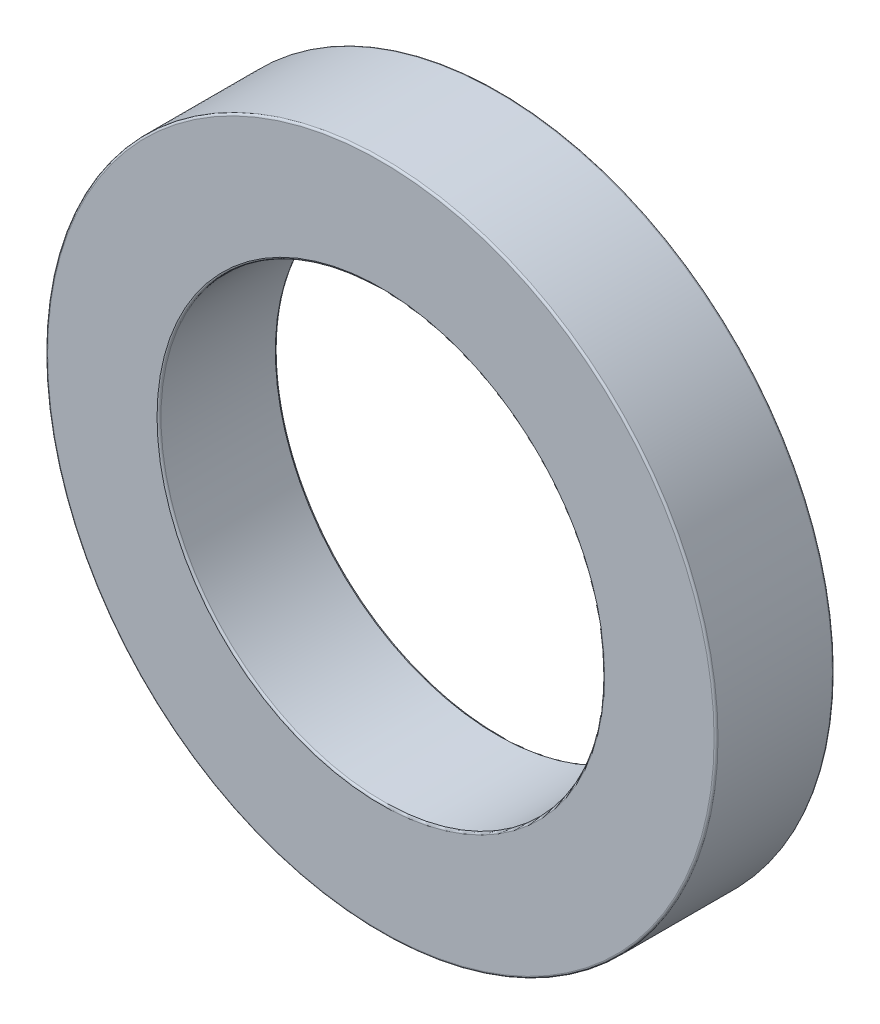
from build123d import *

# Parameters (mm, degrees)
SKETCH_1_R      = 34
SKETCH_1_R_2    = 22.5
EXTRUDE_1_DEPTH = 12
FILLET_1_R      = 0.2


with BuildPart() as part:
    # 스케치1 → 보스-돌출1 (new body)
    with BuildSketch(Plane.XY):
        Circle(SKETCH_1_R)
        Circle(SKETCH_1_R_2, mode=Mode.SUBTRACT)
    extrude(amount=EXTRUDE_1_DEPTH)

    # 필렛1
    fillet_1_edges = [part.edges().sort_by_distance(p)[0] for p in [
        (-34, 0, 0),
        (-34, 0, 12),
        (-22.5, 0, 0),
        (-22.5, 0, 12),
    ]]
    fillet(fillet_1_edges, radius=FILLET_1_R)


solid = part.part
